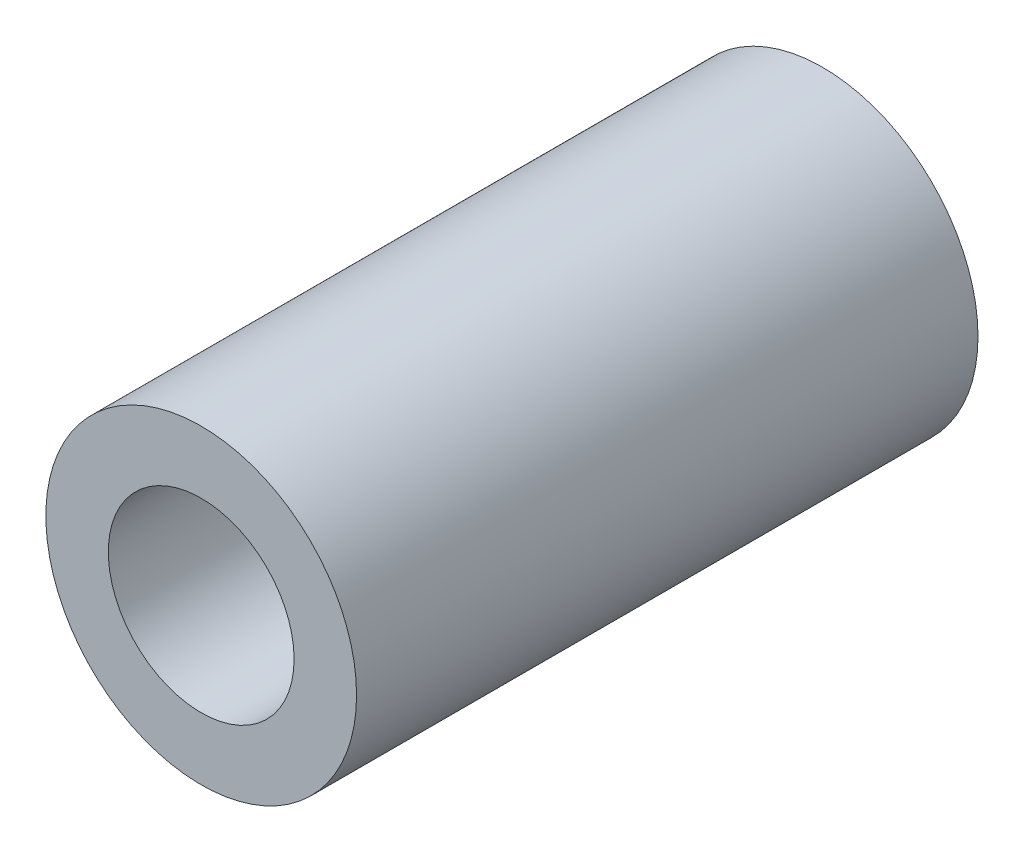
from build123d import *

# Parameters (mm, degrees)
SKETCH1_R             = 3.175
BOSS_EXTRUDE1_DEPTH   = 12.7
F_6_CLEARANCE_HOLE1_D = 3.7973


with BuildPart() as part:
    # Sketch1 → Boss-Extrude1 (new body)
    with BuildSketch(Plane.XY):
        Circle(SKETCH1_R)
    extrude(amount=BOSS_EXTRUDE1_DEPTH)

    # #6 Clearance Hole1 (through all)
    with Locations(Plane.XY.offset(12.7)):
        with Locations((0, 0)):
            Hole(F_6_CLEARANCE_HOLE1_D / 2)


solid = part.part
